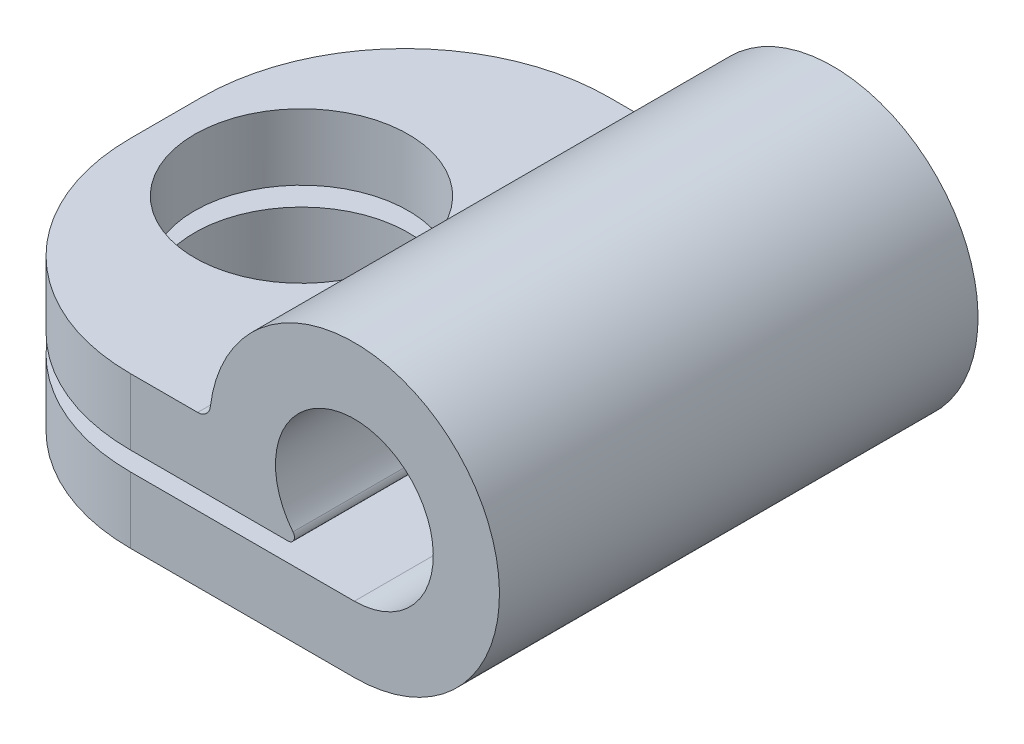
from build123d import *

# Parameters (mm, degrees)
BOSS_EXTRUDE1_DEPTH = 9.4
SKETCH2_R           = 2.1
CUT_EXTRUDE1_DEPTH  = 9.4
FILLET1_R           = 4


with BuildPart() as part:
    # Sketch1 → Boss-Extrude1 (new body)
    with BuildSketch(Plane.XY):
        with BuildLine():
            Line((0, -1.55), (-8.4, -1.55))
            Line((-8.4, -1.55), (-8.4, -2.85))
            Line((-8.4, -2.85), (0, -2.85))
            ThreePointArc((0, -2.85), (2.132811003, 1.89040134), (-2.829381598, 0.342198439))
            ThreePointArc((-2.829381598, 0.342198439), (-2.911748288, 0.185127161), (-3.077572967, 0.122215846))
            Line((-3.077572967, 0.122215846), (-8.4, 0.122215846))
            Line((-8.4, 0.122215846), (-8.4, -1.177784154))
            Line((-8.4, -1.177784154), (-1.302793355, -1.177784154))
            ThreePointArc((-1.302793355, -1.177784154), (-1.189997637, -1.106655539), (-1.20556997, -0.974218173))
            ThreePointArc((-1.20556997, -0.974218173), (0.668005177, 1.398666895), (0, -1.55))
        make_face()
    extrude(amount=BOSS_EXTRUDE1_DEPTH)

    # Sketch2 → Cut-Extrude1 (cut)
    with BuildSketch(Plane(origin=(0, 0.122215846, 0), x_dir=(1, 0, 0), z_dir=(0, 1, 0))):
        with Locations((-5.738786483, -4.7)):
            Circle(SKETCH2_R)
    extrude(amount=-CUT_EXTRUDE1_DEPTH, mode=Mode.SUBTRACT)

    # Fillet1
    fillet1_edges = [part.edges().sort_by_distance(p)[0] for p in [
        (-8.4, -0.527784154, 0),
        (-8.4, -2.2, 0),
        (-8.4, -2.2, 9.4),
        (-8.4, -0.527784154, 9.4),
    ]]
    fillet(fillet1_edges, radius=FILLET1_R)


solid = part.part
